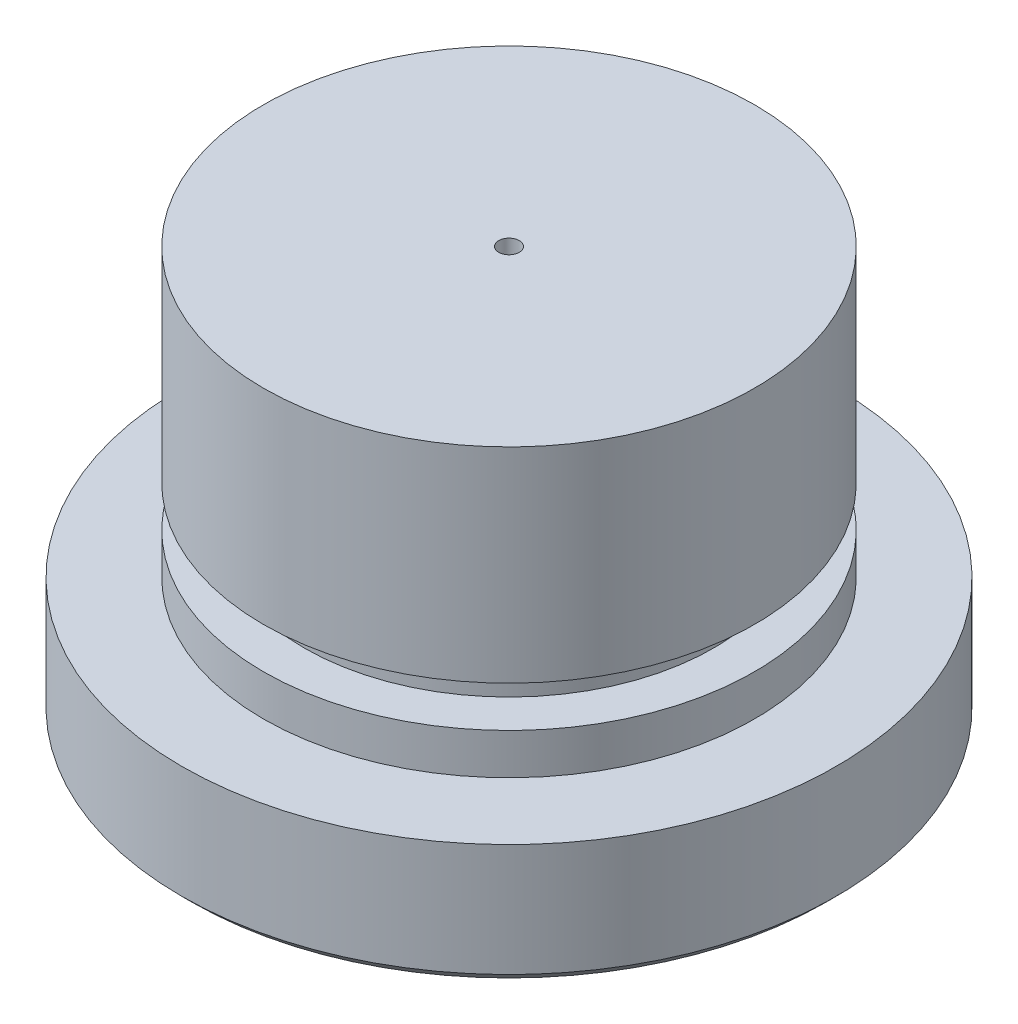
from build123d import *

# Parameters (mm, degrees)
SKETCH1_R           = 12.7
BOSS_EXTRUDE1_DEPTH = 15.875
SKETCH2_R           = 12.7
SKETCH2_R_2         = 9.525
CUT_EXTRUDE1_DEPTH  = 11.1125
SKETCH3_R           = 0.396875
CUT_EXTRUDE2_DEPTH  = 16.875
CHAMFER1_SIZE       = 0.396875
SKETCH4_R           = 9.525
SKETCH4_R_2         = 7.9375
CUT_EXTRUDE3_DEPTH  = 1.5875


with BuildPart() as part:
    # Sketch1 → Boss-Extrude1 (new body)
    with BuildSketch(Plane(origin=(0, 0, 0), x_dir=(1, 0, 0), z_dir=(0, 1, 0))):
        Circle(SKETCH1_R)
    extrude(amount=BOSS_EXTRUDE1_DEPTH)

    # Sketch2 → Cut-Extrude1 (cut)
    with BuildSketch(Plane(origin=(0, 15.875, 0), x_dir=(1, 0, 0), z_dir=(0, 1, 0))):
        Circle(SKETCH2_R)
        Circle(SKETCH2_R_2, mode=Mode.SUBTRACT)
    extrude(amount=-CUT_EXTRUDE1_DEPTH, mode=Mode.SUBTRACT)

    # Sketch3 → Cut-Extrude2 (cut, through all)
    with BuildSketch(Plane.XZ):
        Circle(SKETCH3_R)
    extrude(amount=-CUT_EXTRUDE2_DEPTH, mode=Mode.SUBTRACT)

    # Chamfer1
    chamfer1_edges = [part.edges().sort_by_distance(p)[0] for p in [
        (-12.7, 0, 0),
    ]]
    chamfer(chamfer1_edges, length=CHAMFER1_SIZE)

    # Sketch4 → Cut-Extrude3 (cut)
    with BuildSketch(Plane(origin=(0, 6.35, 0), x_dir=(1, 0, 0), z_dir=(0, 1, 0))):
        Circle(SKETCH4_R)
        Circle(SKETCH4_R_2, mode=Mode.SUBTRACT)
    extrude(amount=CUT_EXTRUDE3_DEPTH, mode=Mode.SUBTRACT)


solid = part.part
